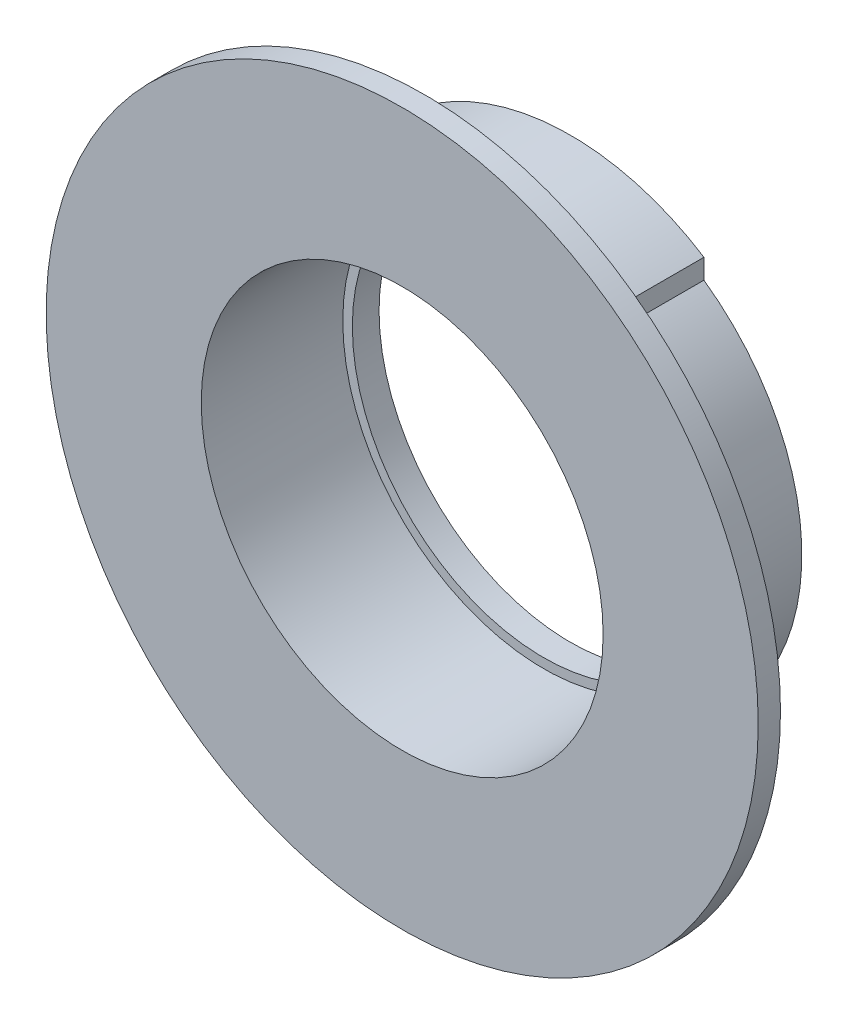
from build123d import *

# Parameters (mm, degrees)
SKETCH1_R           = 27.85
SKETCH1_R_2         = 22.575
BOSS_EXTRUDE1_DEPTH = 16.4
SKETCH2_R           = 40
SKETCH2_R_2         = 22.575
BOSS_EXTRUDE2_DEPTH = 2.5
SKETCH3_R           = 22.575
SKETCH3_R_2         = 21.5
BOSS_EXTRUDE3_DEPTH = 3
CUT_EXTRUDE1_DEPTH  = 16.4


with BuildPart() as part:
    # Sketch1 → Boss-Extrude1 (new body)
    with BuildSketch(Plane.XY):
        Circle(SKETCH1_R)
        Circle(SKETCH1_R_2, mode=Mode.SUBTRACT)
    extrude(amount=BOSS_EXTRUDE1_DEPTH)

    # Sketch2 → Boss-Extrude2 (add)
    with BuildSketch(Plane.XY.offset(16.4)):
        Circle(SKETCH2_R)
        Circle(SKETCH2_R_2, mode=Mode.SUBTRACT)
    extrude(amount=BOSS_EXTRUDE2_DEPTH)

    # Sketch3 → Boss-Extrude3 (add)
    with BuildSketch(Plane(origin=(0, 0, 0), x_dir=(-1, 0, 0), z_dir=(0, 0, -1))):
        Circle(SKETCH3_R)
        Circle(SKETCH3_R_2, mode=Mode.SUBTRACT)
    extrude(amount=-BOSS_EXTRUDE3_DEPTH)

    # Sketch4 → Cut-Extrude1 (cut)
    with BuildSketch(Plane(origin=(0, 0, 0), x_dir=(-1, 0, 0), z_dir=(0, 0, -1))):
        with BuildLine():
            Line((-15, 21.236760582), (-15, 23.465346791))
            ThreePointArc((-15, 23.465346791), (-27.85, 0), (-15, -23.465346791))
            Line((-15, -23.465346791), (-15, -21.236760582))
            ThreePointArc((-15, -21.236760582), (-26, 0), (-15, 21.236760582))
        make_face()
        with BuildLine():
            ThreePointArc((27.85, 0), (24.427162136, 13.376705499), (15, 23.465346791))
            Line((15, 23.465346791), (15, 21.236760582))
            ThreePointArc((15, 21.236760582), (23.086792761, 11.958260743), (26, 0))
            ThreePointArc((26, 0), (23.086792761, -11.958260743), (15, -21.236760582))
            Line((15, -21.236760582), (15, -23.465346791))
            ThreePointArc((15, -23.465346791), (24.427162136, -13.376705499), (27.85, 0))
        make_face()
    extrude(amount=-CUT_EXTRUDE1_DEPTH, mode=Mode.SUBTRACT)


solid = part.part
